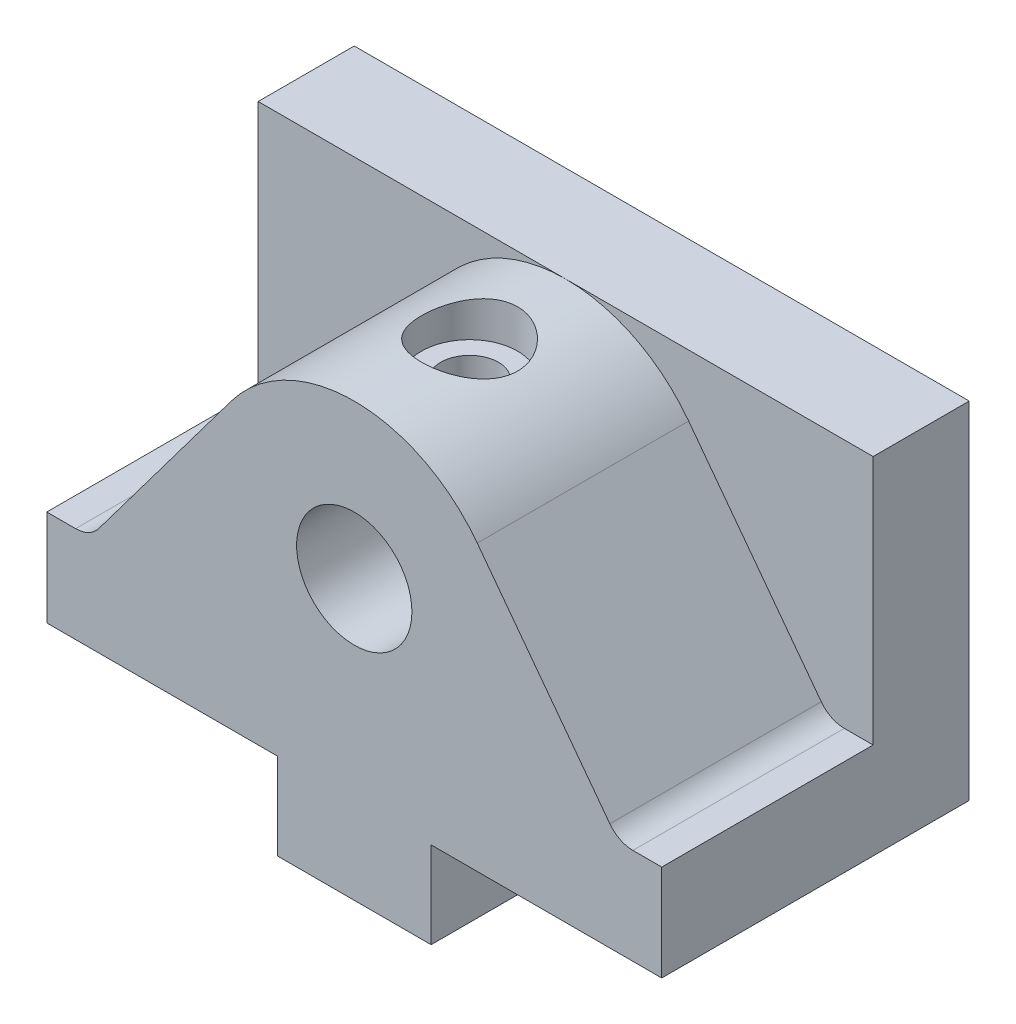
from build123d import *

# Parameters (mm, degrees)
BOSS_EXTRUDE1_DEPTH            = 32
SKETCH2_R                      = 6
CUT_EXTRUDE1_DEPTH             = 22
SKETCH3_R                      = 5
CUT_EXTRUDE2_DEPTH             = 4
CUT_EXTRUDE3_REACH             = 43
SKETCH4_R                      = 3
CUT_EXTRUDE3_DIRECTION_2_DEPTH = 5.0000001
SKETCH5_R                      = 3
CUT_EXTRUDE4_DEPTH             = 16


with BuildPart() as part:
    # Sketch1 → Boss-Extrude1 (new body)
    with BuildSketch(Plane.XY):
        Polygon((40, 0), (64, 0), (64, 36), (0, 36), (0, 0), (24, 0), (24, -9), (40, -9), align=None)
    extrude(amount=BOSS_EXTRUDE1_DEPTH)

    # Sketch2 → Cut-Extrude1 (cut)
    with BuildSketch(Plane.XY.offset(32)):
        with BuildLine():
            Line((0, 36), (0, 10))
            Line((0, 10), (3, 10))
            ThreePointArc((3, 10), (4.341640786, 10.316718427), (5.4, 11.2))
            Line((5.4, 11.2), (19.2, 29.6))
            ThreePointArc((19.2, 29.6), (24.844582472, 34.310835056), (32, 36))
            Line((32, 36), (0, 36))
        make_face()
        with BuildLine():
            Line((64, 36), (32, 36))
            ThreePointArc((32, 36), (39.155417528, 34.310835056), (44.8, 29.6))
            Line((44.8, 29.6), (58.6, 11.2))
            ThreePointArc((58.6, 11.2), (59.658359214, 10.316718427), (61, 10))
            Line((61, 10), (64, 10))
            Line((64, 10), (64, 36))
        make_face()
        with Locations((32, 20)):
            Circle(SKETCH2_R)
    extrude(amount=-CUT_EXTRUDE1_DEPTH, mode=Mode.SUBTRACT)

    # Sketch3 → Cut-Extrude2 (cut)
    with BuildSketch(Plane(origin=(0, 36, 0), x_dir=(1, 0, 0), z_dir=(0, 1, 0))):
        with Locations((32, -20)):
            Circle(SKETCH3_R)
    extrude(amount=-CUT_EXTRUDE2_DEPTH, mode=Mode.SUBTRACT)

    # Sketch4 → Cut-Extrude3 (cut, up to next)
    with BuildSketch(Plane(origin=(0, 32, 0), x_dir=(1, 0, 0), z_dir=(0, 1, 0)), mode=Mode.PRIVATE) as cut_extrude3_sk1:
        with Locations((32, -20)):
            Circle(SKETCH4_R)
    cut_extrude3_tool1 = extrude(cut_extrude3_sk1.sketch, amount=-CUT_EXTRUDE3_REACH, mode=Mode.PRIVATE) & part.part
    add(cut_extrude3_tool1.solids().sort_by_distance((32, 32, 20))[0], mode=Mode.SUBTRACT)

    # Sketch4 → Cut-Extrude3 direction 2 (cut)
    with BuildSketch(Plane(origin=(0, 32, 0), x_dir=(1, 0, 0), z_dir=(0, 1, 0))):
        with Locations((32, -20)):
            Circle(SKETCH4_R)
    extrude(amount=CUT_EXTRUDE3_DIRECTION_2_DEPTH, mode=Mode.SUBTRACT)

    # Sketch5 → Cut-Extrude4 (cut)
    with BuildSketch(Plane.XZ.offset(9)):
        with Locations((32, 24)):
            Circle(SKETCH5_R)
        with Locations((32, 8)):
            Circle(SKETCH5_R)
    extrude(amount=-CUT_EXTRUDE4_DEPTH, mode=Mode.SUBTRACT)


solid = part.part
